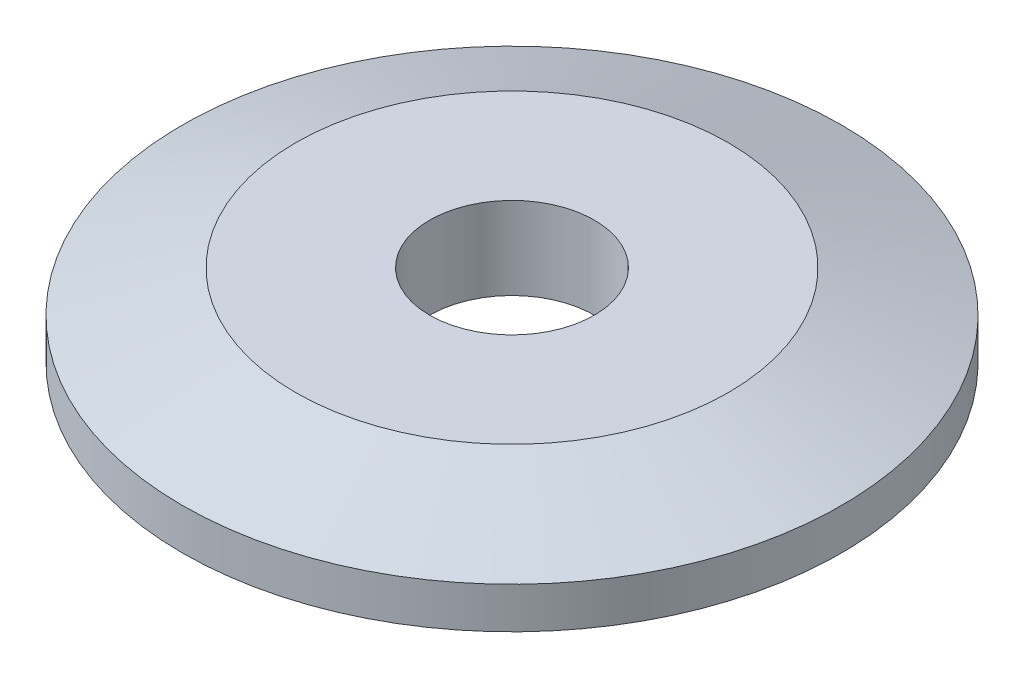
from build123d import *

# Parameters (mm, degrees)
SKETCH1_R           = 8
BOSS_EXTRUDE1_DEPTH = 2
CHAMFER1_SIZE       = 1
CHAMFER1_SIZE2      = 2.747477419
SKETCH2_R           = 2
CUT_EXTRUDE1_DEPTH  = 3


with BuildPart() as part:
    # Sketch1 → Boss-Extrude1 (new body)
    with BuildSketch(Plane(origin=(0, 0, 0), x_dir=(1, 0, 0), z_dir=(0, 1, 0))):
        Circle(SKETCH1_R)
    extrude(amount=BOSS_EXTRUDE1_DEPTH)

    # Chamfer1
    chamfer1_edges = [part.edges().sort_by_distance(p)[0] for p in [
        (-8, 2, 0),
    ]]
    chamfer1_side = [part.faces().sort_by_distance(p)[0] for p in [
        (-8, 1, 0),
    ]]
    chamfer(chamfer1_edges, length=CHAMFER1_SIZE, length2=CHAMFER1_SIZE2, reference=chamfer1_side[0])

    # Sketch2 → Cut-Extrude1 (cut, through all)
    with BuildSketch(Plane(origin=(0, 2, 0), x_dir=(1, 0, 0), z_dir=(0, 1, 0))):
        Circle(SKETCH2_R)
    extrude(amount=-CUT_EXTRUDE1_DEPTH, mode=Mode.SUBTRACT)


solid = part.part
